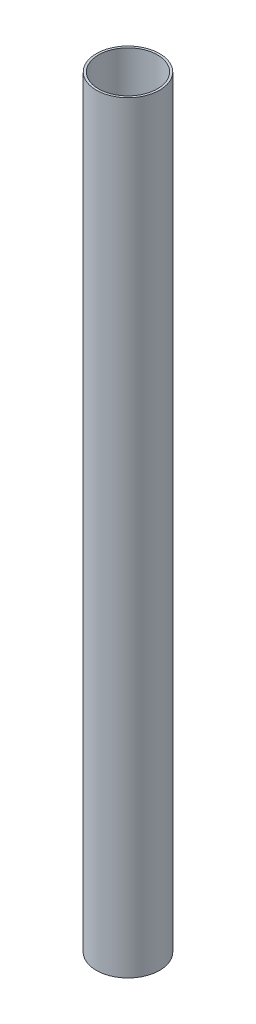
from build123d import *

# Parameters (mm, degrees)
DRIVER_R     = 29.083
DRIVER_R_2   = 27.06751
AERO_DEPTH   = 700
DRIVER_3_R   = 20.6
DRIVER_3_R_2 = 19
MOTOR_DEPTH  = 600


with BuildPart() as part:
    # driver → aero (new body)
    with BuildSketch(Plane(origin=(0, 0, 0), x_dir=(1, 0, 0), z_dir=(0, 1, 0))):
        Circle(DRIVER_R)
        Circle(DRIVER_R_2, mode=Mode.SUBTRACT)
    extrude(amount=AERO_DEPTH)


with BuildPart() as body_2:
    # driver_3 → motor (new body)
    with BuildSketch(Plane(origin=(0, 0, 0), x_dir=(1, 0, 0), z_dir=(0, 1, 0))):
        Circle(DRIVER_3_R)
        Circle(DRIVER_3_R_2, mode=Mode.SUBTRACT)
    extrude(amount=MOTOR_DEPTH)


solid = Compound([part.part, body_2.part])
